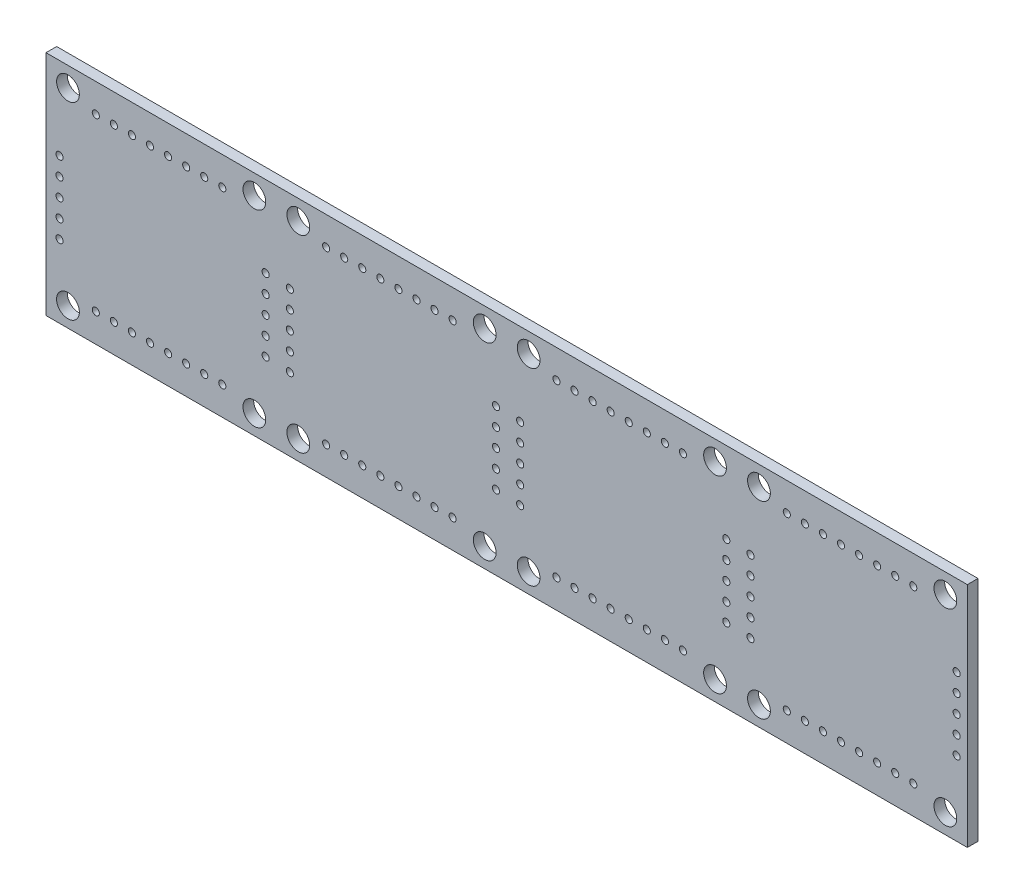
from build123d import *

# Parameters (mm, degrees)
SKETCH1_W                  = 32.375
SKETCH1_H                  = 32
SKETCH1_R                  = 1.6
BOSS_EXTRUDE1_DEPTH        = 1.5
SKETCH3_R                  = 0.5
CUT_EXTRUDE1_DEPTH         = 1.5
R_P_TITION_LIN_AIRE1_COUNT = 4
R_P_TITION_LIN_AIRE1_PITCH = 32.375


with BuildPart() as part:
    # Sketch1 → Boss-Extrude1 (new body)
    with BuildSketch(Plane.XY):
        Rectangle(SKETCH1_W, SKETCH1_H)
        with Locations((-13.1, -13.25)):
            Circle(SKETCH1_R, mode=Mode.SUBTRACT)
        with Locations((13.1, -13.25)):
            Circle(SKETCH1_R, mode=Mode.SUBTRACT)
        with Locations((13.1, 13.25)):
            Circle(SKETCH1_R, mode=Mode.SUBTRACT)
        with Locations((-13.1, 13.25)):
            Circle(SKETCH1_R, mode=Mode.SUBTRACT)
    boss_extrude1 = extrude(amount=BOSS_EXTRUDE1_DEPTH)

    # Sketch3 → Cut-Extrude1 (cut)
    with BuildSketch(Plane(origin=(0, 0, 0), x_dir=(-1, 0, 0), z_dir=(0, 0, -1))):
        with Locations((-14.6875, 4.6)):
            Circle(SKETCH3_R)
        with Locations((-14.6875, 2.06)):
            Circle(SKETCH3_R)
        with Locations((-14.6875, -0.48)):
            Circle(SKETCH3_R)
        with Locations((-14.6875, -3.02)):
            Circle(SKETCH3_R)
        with Locations((-14.6875, -5.56)):
            Circle(SKETCH3_R)
        with Locations((9.1875, 12)):
            Circle(SKETCH3_R)
        with Locations((6.6475, 12)):
            Circle(SKETCH3_R)
        with Locations((4.1075, 12)):
            Circle(SKETCH3_R)
        with Locations((1.5675, 12)):
            Circle(SKETCH3_R)
        with Locations((-0.9725, 12)):
            Circle(SKETCH3_R)
        with Locations((-3.5125, 12)):
            Circle(SKETCH3_R)
        with Locations((-6.0525, 12)):
            Circle(SKETCH3_R)
        with Locations((-8.5925, 12)):
            Circle(SKETCH3_R)
        with Locations((9.1875, -12)):
            Circle(SKETCH3_R)
        with Locations((6.6475, -12)):
            Circle(SKETCH3_R)
        with Locations((4.1075, -12)):
            Circle(SKETCH3_R)
        with Locations((1.5675, -12)):
            Circle(SKETCH3_R)
        with Locations((-0.9725, -12)):
            Circle(SKETCH3_R)
        with Locations((-3.5125, -12)):
            Circle(SKETCH3_R)
        with Locations((-6.0525, -12)):
            Circle(SKETCH3_R)
        with Locations((-8.5925, -12)):
            Circle(SKETCH3_R)
        with Locations((14.2875, 4.4)):
            Circle(SKETCH3_R)
        with Locations((14.2875, 1.86)):
            Circle(SKETCH3_R)
        with Locations((14.2875, -0.68)):
            Circle(SKETCH3_R)
        with Locations((14.2875, -3.22)):
            Circle(SKETCH3_R)
        with Locations((14.2875, -5.76)):
            Circle(SKETCH3_R)
    cut_extrude1 = extrude(amount=-CUT_EXTRUDE1_DEPTH, mode=Mode.SUBTRACT)

    # Répétition linéaire1: Boss-Extrude1, Cut-Extrude1 ×4
    with Locations(*[(i * R_P_TITION_LIN_AIRE1_PITCH, 0, 0) for i in range(1, R_P_TITION_LIN_AIRE1_COUNT)]):
        add(boss_extrude1)
        add(cut_extrude1, mode=Mode.SUBTRACT)


solid = part.part
